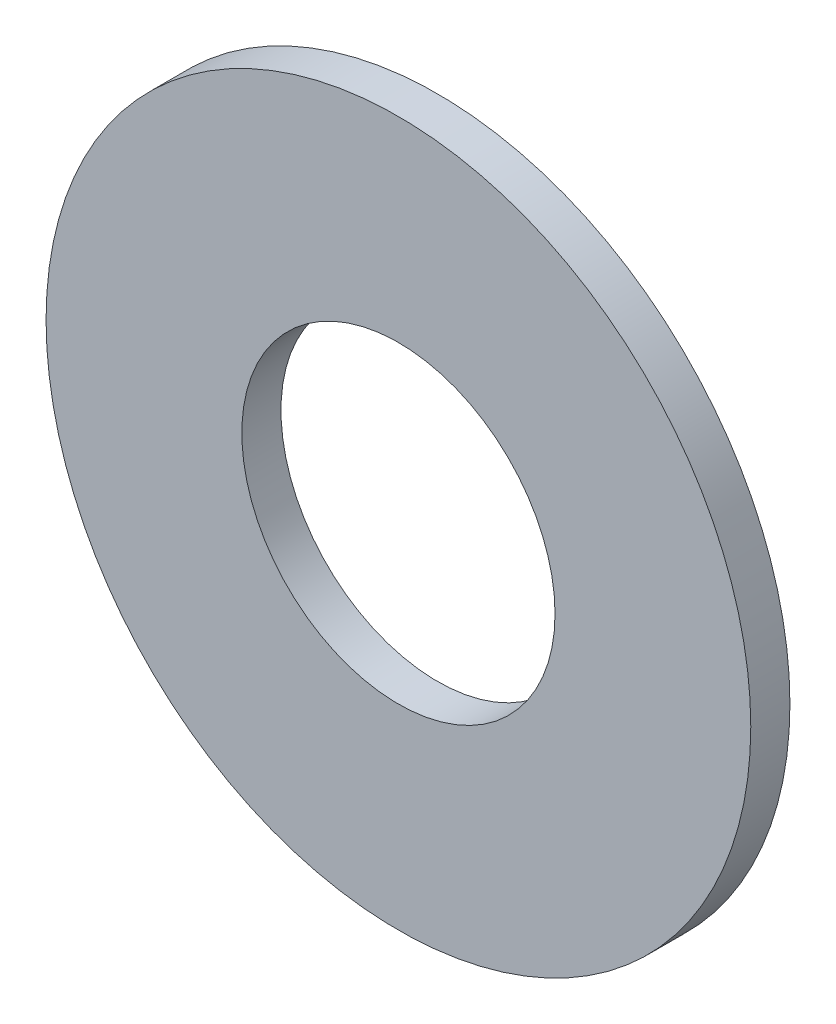
from build123d import *

# Parameters (mm, degrees)
SKETCH_1_R      = 4.5
SKETCH_1_R_2    = 2
EXTRUDE_1_DEPTH = 0.5


with BuildPart() as part:
    # 草图1 → 凸台-拉伸1 (new body)
    with BuildSketch(Plane.XY):
        Circle(SKETCH_1_R)
        Circle(SKETCH_1_R_2, mode=Mode.SUBTRACT)
    extrude(amount=EXTRUDE_1_DEPTH)


solid = part.part
